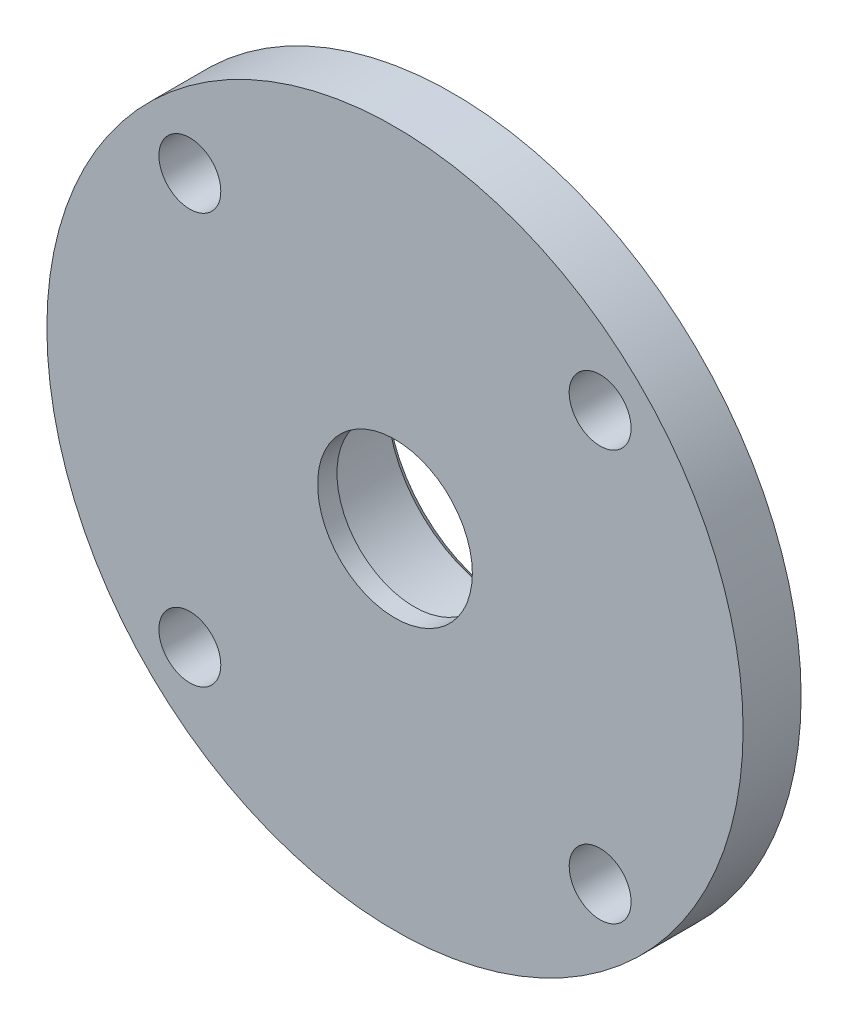
from build123d import *

# Parameters (mm, degrees)
SKETCH_2_R               = 1.6
CUT_EXTRUDE_1_DEPTH      = 3
PATTERN_CIRCULAR_1_COUNT = 4
CHAMFER_1_SIZE           = 0.4


with BuildPart() as part:
    # Эскиз1 → Повернуть1 (revolve)
    with BuildSketch(Plane(origin=(0, 0, 0), x_dir=(1, 0, 0), z_dir=(0, 1, 0))):
        Polygon((-4, 0), (-18, 0), (-18, 3), (-9.5, 3), (-9.5, 6), (-6, 6), (-6, 1), (-4, 1), align=None)
    revolve(axis=Axis((0, 0, 0), (0, 0, -1)))

    # Эскиз2 → Вырез-Вытянуть1 (cut)
    with BuildSketch(Plane.XY):
        with Locations((10.606601718, 10.606601718)):
            Circle(SKETCH_2_R)
    cut_extrude_1 = extrude(amount=-CUT_EXTRUDE_1_DEPTH, mode=Mode.SUBTRACT)

    # Круговой массив1: Вырез-Вытянуть1 ×4 about axis
    pattern_circular_1_axis = Axis((0, 0, 0), (0, 0, 1))
    for i in range(1, PATTERN_CIRCULAR_1_COUNT):
        add(cut_extrude_1.rotate(pattern_circular_1_axis, i * 360 / PATTERN_CIRCULAR_1_COUNT), mode=Mode.SUBTRACT)

    # Фаска1
    chamfer_1_edges = [part.edges().sort_by_distance(p)[0] for p in [
        (6, 0, -6),
        (9.5, 0, -6),
    ]]
    chamfer(chamfer_1_edges, length=CHAMFER_1_SIZE)


solid = part.part
